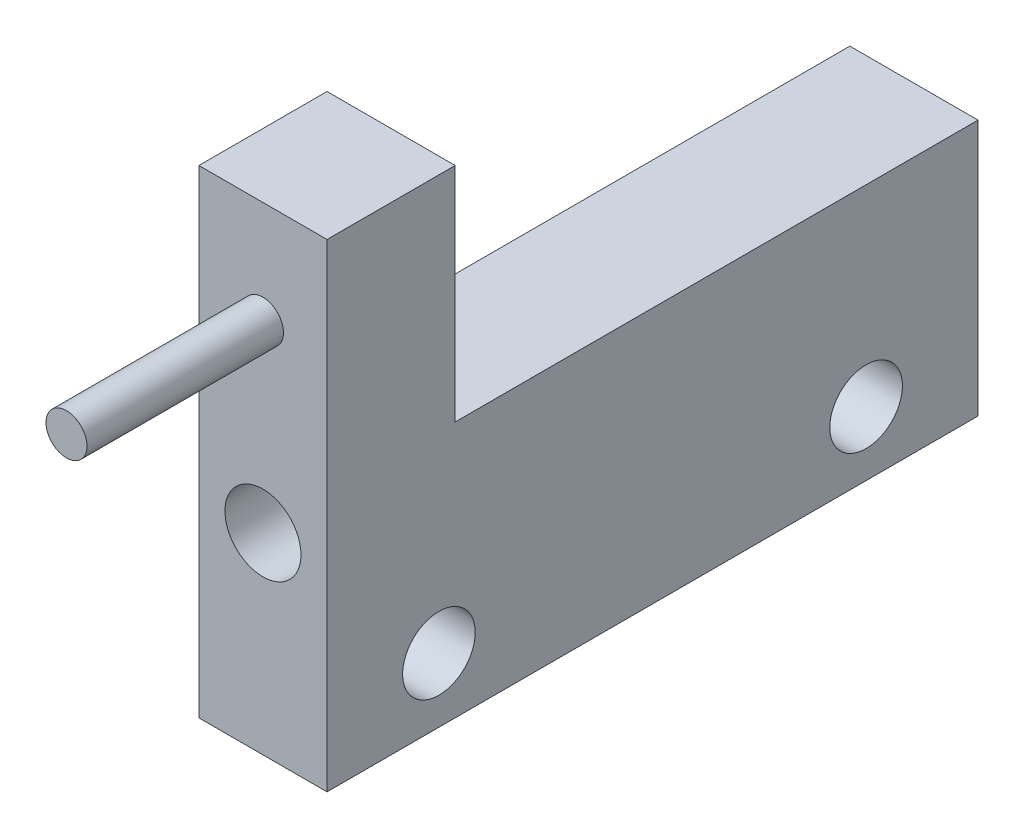
from build123d import *

# Parameters (mm, degrees)
SKETCH2_W           = 15
SKETCH2_H           = 30
SKETCH2_R           = 4.45
BOSS_EXTRUDE1_DEPTH = 76.2
SKETCH3_R           = 4.25
CUT_EXTRUDE2_DEPTH  = 16
SKETCH5_W           = 15
SKETCH5_H           = 26
BOSS_EXTRUDE3_DEPTH = 15
SKETCH8_R           = 2.4
BOSS_EXTRUDE4_DEPTH = 23


with BuildPart() as part:
    # Sketch2 → Boss-Extrude1 (new body)
    with BuildSketch(Plane.XY):
        with Locations((-10.953990987, 24.19276181)):
            Rectangle(SKETCH2_W, SKETCH2_H)
        with Locations((-10.953990987, 31.69276181)):
            Circle(SKETCH2_R, mode=Mode.SUBTRACT)
    extrude(amount=BOSS_EXTRUDE1_DEPTH)

    # Sketch3 → Cut-Extrude2 (cut, through all)
    with BuildSketch(Plane(origin=(-3.453990987, 0, 0), x_dir=(0, 0, -1), z_dir=(1, 0, 0))):
        with Locations((-63.1, 16.69276181)):
            Circle(SKETCH3_R)
        with Locations((-13.1, 16.69276181)):
            Circle(SKETCH3_R)
    extrude(amount=-CUT_EXTRUDE2_DEPTH, mode=Mode.SUBTRACT)

    # Sketch5 → Boss-Extrude3 (add)
    with BuildSketch(Plane.XY.offset(76.2)):
        with Locations((-10.953990987, 52.19276181)):
            Rectangle(SKETCH5_W, SKETCH5_H)
    extrude(amount=-BOSS_EXTRUDE3_DEPTH)

    # Sketch8 → Boss-Extrude4 (add)
    with BuildSketch(Plane.XY.offset(76.2)):
        with Locations((-10.953990987, 53.19276181)):
            Circle(SKETCH8_R)
    extrude(amount=BOSS_EXTRUDE4_DEPTH)


solid = part.part
